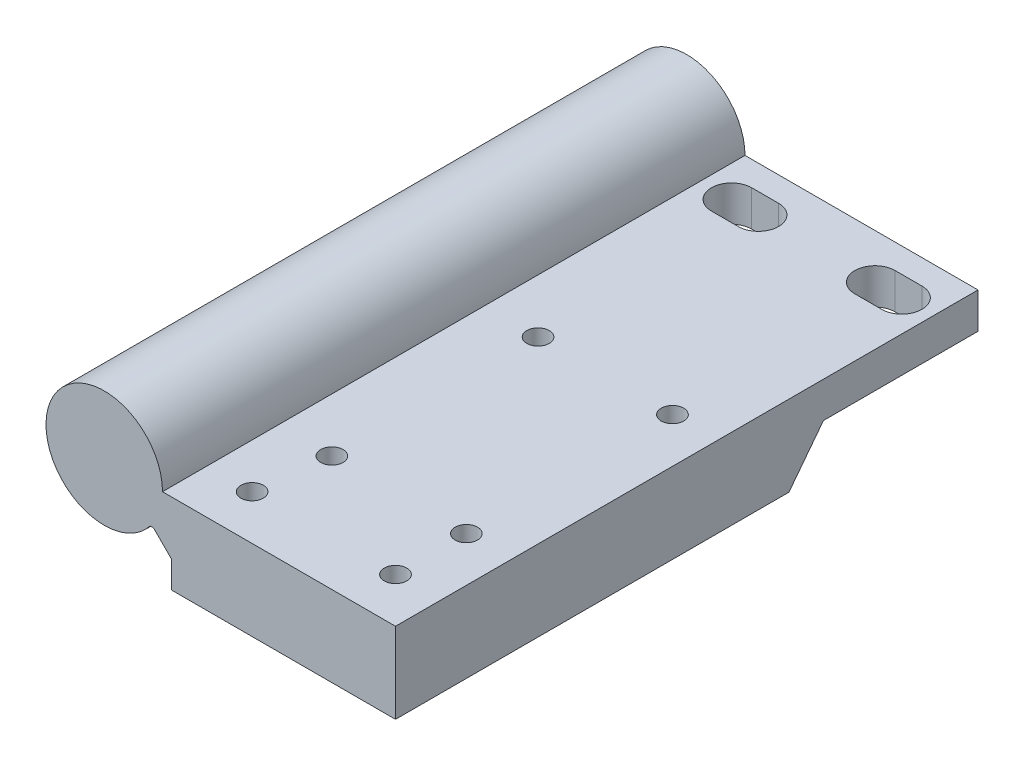
from build123d import *

# Parameters (mm, degrees)
SKETCH_1_R           = 4.1
EXTRUDE_1_DEPTH      = 65
SKETCH_2_R           = 4.923200542
EXTRUDE_2_DEPTH      = 3
SKETCH_3_R           = 1.25
CUT_EXTRUDE_1_DEPTH  = 13
EXTRUDE_3_DEPTH      = 12.5
EXTRUDE_3_DEPTH_BACK = 12.5
CHAMFER_4_SIZE       = 2
SKETCH_5_R           = 1.25
CUT_EXTRUDE_2_DEPTH  = 10


with BuildPart() as part:
    # Эскиз1 → Бобышка-Вытянуть1 (new body)
    with BuildSketch(Plane.XY):
        with BuildLine():
            Line((5.123475383, -4), (32.5, -4))
            Line((32.5, -4), (32.5, 0))
            Line((32.5, 0), (6.5, 0))
            ThreePointArc((6.5, 0), (-6.146242348, 2.115113473), (5.123475383, -4))
        make_face()
        Circle(SKETCH_1_R, mode=Mode.SUBTRACT)
    extrude(amount=EXTRUDE_1_DEPTH)

    # Эскиз2 → Бобышка-Вытянуть2 (add)
    with BuildSketch(Plane.XY.offset(65)):
        Circle(SKETCH_2_R)
    extrude(amount=-EXTRUDE_2_DEPTH)

    # Эскиз3 → Вырез-Вытянуть1 (cut)
    with BuildSketch(Plane(origin=(0, 0, 0), x_dir=(1, 0, 0), z_dir=(0, 1, 0))):
        with Locations((11.5, -60)):
            Circle(SKETCH_3_R)
        with Locations((27.5, -60)):
            Circle(SKETCH_3_R)
        with BuildLine():
            Line((10, -7.25), (13, -7.25))
            ThreePointArc((13, -7.25), (15.25, -5), (13, -2.75))
            Line((13, -2.75), (10, -2.75))
            ThreePointArc((10, -2.75), (7.75, -5), (10, -7.25))
        make_face()
        with BuildLine():
            Line((26, -2.75), (29, -2.75))
            ThreePointArc((29, -2.75), (31.25, -5), (29, -7.25))
            Line((29, -7.25), (26, -7.25))
            ThreePointArc((26, -7.25), (23.75, -5), (26, -2.75))
        make_face()
    extrude(amount=-CUT_EXTRUDE_1_DEPTH, mode=Mode.SUBTRACT)

    # Эскиз4 → Бобышка-Вытянуть3 (add, two sides: drawn at the far end of the back side and taken through both)
    with BuildSketch(Plane(origin=(20, 0, 0), x_dir=(0, 0, -1), z_dir=(1, 0, 0)).offset(-EXTRUDE_3_DEPTH_BACK)):
        Polygon((-17.25, -4), (-21.094184264, -9), (-65, -9), (-65, -4), align=None)
    extrude(amount=EXTRUDE_3_DEPTH + EXTRUDE_3_DEPTH_BACK)

    # Фаска4
    chamfer_4_edges = [part.edges().sort_by_distance(p)[0] for p in [
        (7.5, -4, 41.125),
    ]]
    chamfer(chamfer_4_edges, length=CHAMFER_4_SIZE)

    # Эскиз5 → Вырез-Вытянуть2 (cut)
    with BuildSketch(Plane.XZ.offset(9)):
        with Locations((27.5, 29.094184264)):
            Circle(SKETCH_5_R)
        with Locations((12.5, 29.094184264)):
            Circle(SKETCH_5_R)
        with Locations((27.5, 52.094184264)):
            Circle(SKETCH_5_R)
        with Locations((12.5, 52.094184264)):
            Circle(SKETCH_5_R)
    extrude(amount=-CUT_EXTRUDE_2_DEPTH, mode=Mode.SUBTRACT)


solid = part.part
